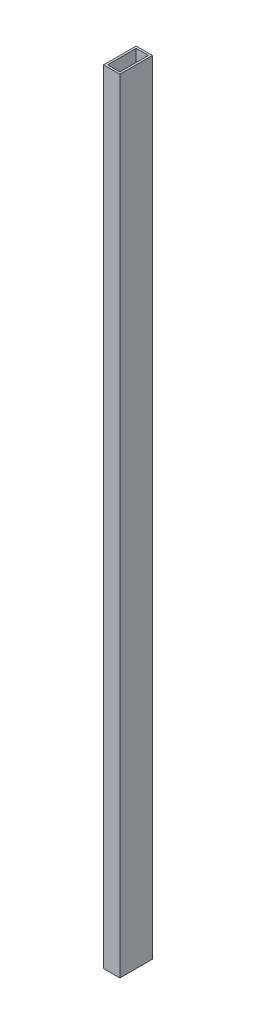
from build123d import *

# Parameters (mm, degrees)
SKETCH1_W           = 25.4
SKETCH1_H           = 50.8
SKETCH1_W_2         = 19.05
SKETCH1_H_2         = 44.45
BOSS_EXTRUDE1_DEPTH = 1219.2


with BuildPart() as part:
    # Sketch1 → Boss-Extrude1 (new body)
    with BuildSketch(Plane(origin=(0, 0, 0), x_dir=(1, 0, 0), z_dir=(0, 1, 0))):
        with Locations((12.7, 25.4)):
            Rectangle(SKETCH1_W, SKETCH1_H)
        with Locations((12.7, 25.4)):
            Rectangle(SKETCH1_W_2, SKETCH1_H_2, mode=Mode.SUBTRACT)
    extrude(amount=BOSS_EXTRUDE1_DEPTH)


solid = part.part
